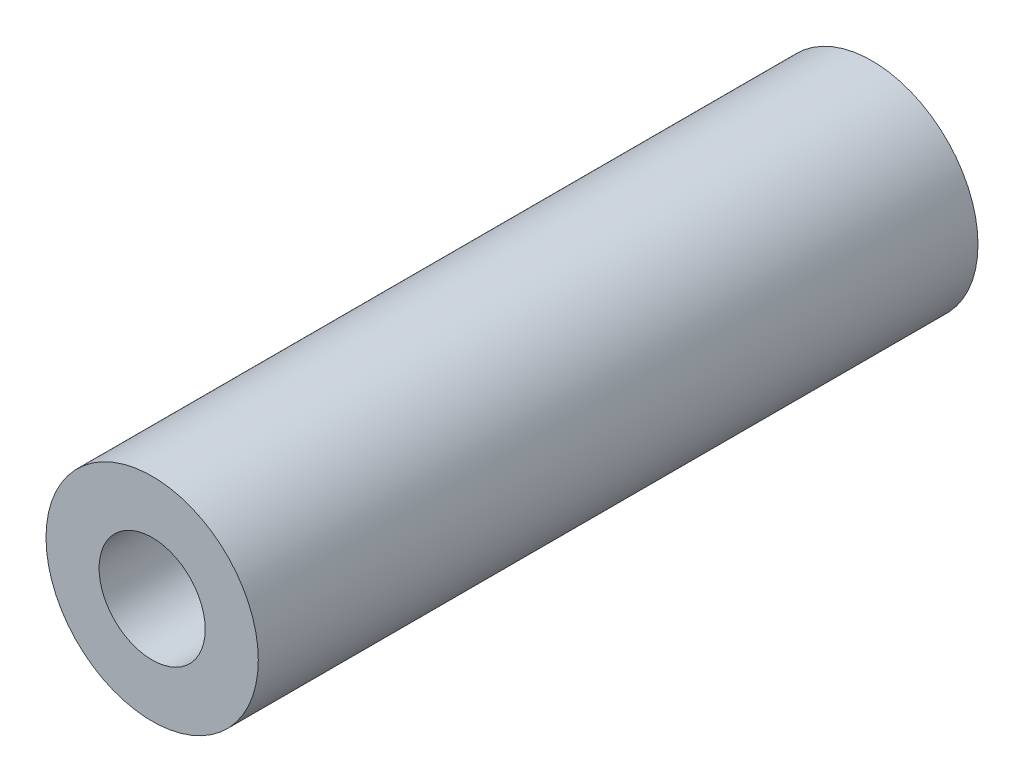
from build123d import *

# Parameters (mm, degrees)
SKETCH1_R                 = 5
BOSS_EXTRUDE1_DEPTH       = 33.9
F_5_0MM_DOWEL_HOLE1_D     = 5
F_5_0MM_DOWEL_HOLE1_DEPTH = 33.9


with BuildPart() as part:
    # Sketch1 → Boss-Extrude1 (new body)
    with BuildSketch(Plane.XY):
        Circle(SKETCH1_R)
    extrude(amount=BOSS_EXTRUDE1_DEPTH)

    # Ø5.0mm Dowel Hole1
    with Locations(Plane.XY.offset(33.9)):
        with Locations((0, 0)):
            Hole(F_5_0MM_DOWEL_HOLE1_D / 2, depth=F_5_0MM_DOWEL_HOLE1_DEPTH)


solid = part.part
